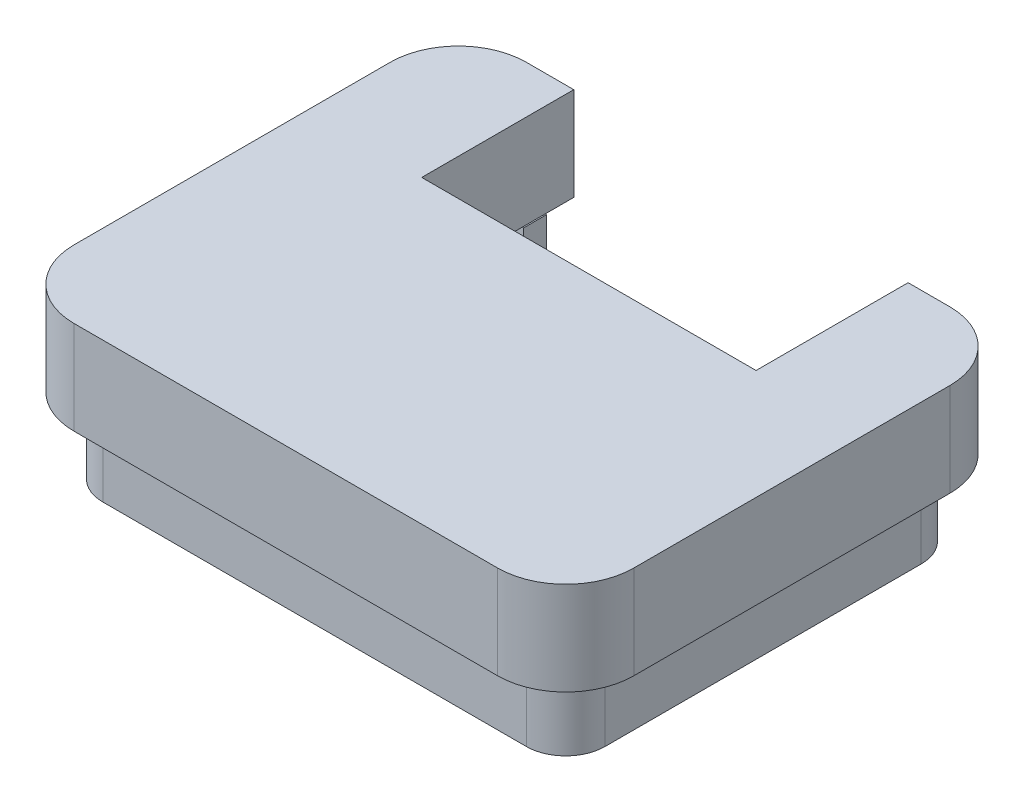
from build123d import *

# Parameters (mm, degrees)
EXTRUDE_3_DEPTH = 1.169927
EXTRUDE_4_DEPTH = 5
EXTRUDE_5_DEPTH = 5


with BuildPart() as part:
    # 草图2 → 凸台-拉伸3 (new body)
    with BuildSketch(Plane(origin=(0, 15, 0), x_dir=(1, 0, 0), z_dir=(0, 1, 0))):
        with BuildLine():
            Line((-24.853345035, 10.461479878), (-24.853345035, 0.41148))
            Line((-24.853345035, 0.41148), (-2.753344966, 0.41148))
            Line((-2.753344966, 0.41148), (-2.753344966, 10.461479878))
            Line((-2.753344966, 10.461479878), (0.013999939, 10.461479878))
            ThreePointArc((0.013999939, 10.461479878), (3.195980454, 9.143460393), (4.513999939, 5.961479878))
            Line((4.513999939, 5.961479878), (4.513999939, -14.938520122))
            ThreePointArc((4.513999939, -14.938520122), (3.195980454, -18.120500638), (0.013999939, -19.438520122))
            Line((0.013999939, -19.438520122), (-27.986000061, -19.438520122))
            ThreePointArc((-27.986000061, -19.438520122), (-31.167980576, -18.120500638), (-32.486000061, -14.938520122))
            Line((-32.486000061, -14.938520122), (-32.486000061, 5.961479878))
            ThreePointArc((-32.486000061, 5.961479878), (-31.167980576, 9.143460393), (-27.986000061, 10.461479878))
            Line((-27.986000061, 10.461479878), (-24.853345035, 10.461479878))
        make_face()
    extrude(amount=EXTRUDE_3_DEPTH)

    # 草图4 → 凸台-拉伸4 (add)
    with BuildSketch(Plane.XZ.offset(-15)):
        with BuildLine():
            Line((-23.193000031, 0.4), (-28.386000061, 0.4))
            Line((-28.386000061, 0.4), (-28.386000061, -0.81148))
            Line((-28.386000061, -0.81148), (-24.853345035, -0.81148))
            Line((-24.853345035, -0.81148), (-24.853345035, -10.461479878))
            Line((-24.853345035, -10.461479878), (-27.986000061, -10.461479878))
            ThreePointArc((-27.986000061, -10.461479878), (-31.167980576, -9.143460393), (-32.486000061, -5.961479878))
            Line((-32.486000061, -5.961479878), (-32.486000061, 14.938520122))
            ThreePointArc((-32.486000061, 14.938520122), (-31.167980576, 18.120500638), (-27.986000061, 19.438520122))
            Line((-27.986000061, 19.438520122), (0.013999939, 19.438520122))
            ThreePointArc((0.013999939, 19.438520122), (3.195980454, 18.120500638), (4.513999939, 14.938520122))
            Line((4.513999939, 14.938520122), (4.513999939, -5.961479878))
            ThreePointArc((4.513999939, -5.961479878), (3.195980454, -9.143460393), (0.013999939, -10.461479878))
            Line((0.013999939, -10.461479878), (-2.753344966, -10.461479878))
            Line((-2.753344966, -10.461479878), (-2.753344966, -0.81148))
            Line((-2.753344966, -0.81148), (0.4, -0.81148))
            Line((0.4, -0.81148), (0.4, 0.4))
            Line((0.4, 0.4), (-5.193000031, 0.4))
            Line((-5.193000031, 0.4), (-5.193000031, 3.4))
            Line((-5.193000031, 3.4), (-23.193000031, 3.4))
            Line((-23.193000031, 3.4), (-23.193000031, 0.4))
        make_face()
    extrude(amount=EXTRUDE_4_DEPTH)

    # 草图5 → 凸台-拉伸5 (add)
    with BuildSketch(Plane.XZ.offset(-10)):
        with BuildLine():
            Line((-2.753344966, -8.561479878), (0.013999939, -8.561479878))
            ThreePointArc((0.013999939, -8.561479878), (1.85247757, -7.799957509), (2.613999939, -5.961479878))
            Line((2.613999939, -5.961479878), (2.613999939, 14.938520122))
            ThreePointArc((2.613999939, 14.938520122), (1.85247757, 16.776997753), (0.013999939, 17.538520122))
            Line((0.013999939, 17.538520122), (-27.986000061, 17.538520122))
            ThreePointArc((-27.986000061, 17.538520122), (-29.824477692, 16.776997753), (-30.586000061, 14.938520122))
            Line((-30.586000061, 14.938520122), (-30.586000061, -5.961479878))
            ThreePointArc((-30.586000061, -5.961479878), (-29.824477692, -7.799957509), (-27.986000061, -8.561479878))
            Line((-27.986000061, -8.561479878), (-24.768224203, -8.561479878))
            Line((-24.768224203, -8.561479878), (-24.768224203, -7.061479878))
            Line((-24.768224203, -7.061479878), (-27.986000061, -7.061479878))
            ThreePointArc((-27.986000061, -7.061479878), (-28.76381752, -6.739297337), (-29.086000061, -5.961479878))
            Line((-29.086000061, -5.961479878), (-29.086000061, 14.938520122))
            ThreePointArc((-29.086000061, 14.938520122), (-28.76381752, 15.716337581), (-27.986000061, 16.038520122))
            Line((-27.986000061, 16.038520122), (0.013999939, 16.038520122))
            ThreePointArc((0.013999939, 16.038520122), (0.791817398, 15.716337581), (1.113999939, 14.938520122))
            Line((1.113999939, 14.938520122), (1.113999939, -5.961479878))
            ThreePointArc((1.113999939, -5.961479878), (0.791817398, -6.739297337), (0.013999939, -7.061479878))
            Line((0.013999939, -7.061479878), (-2.753344966, -7.061479878))
            Line((-2.753344966, -7.061479878), (-2.753344966, -8.561479878))
        make_face()
    extrude(amount=EXTRUDE_5_DEPTH)


solid = part.part
